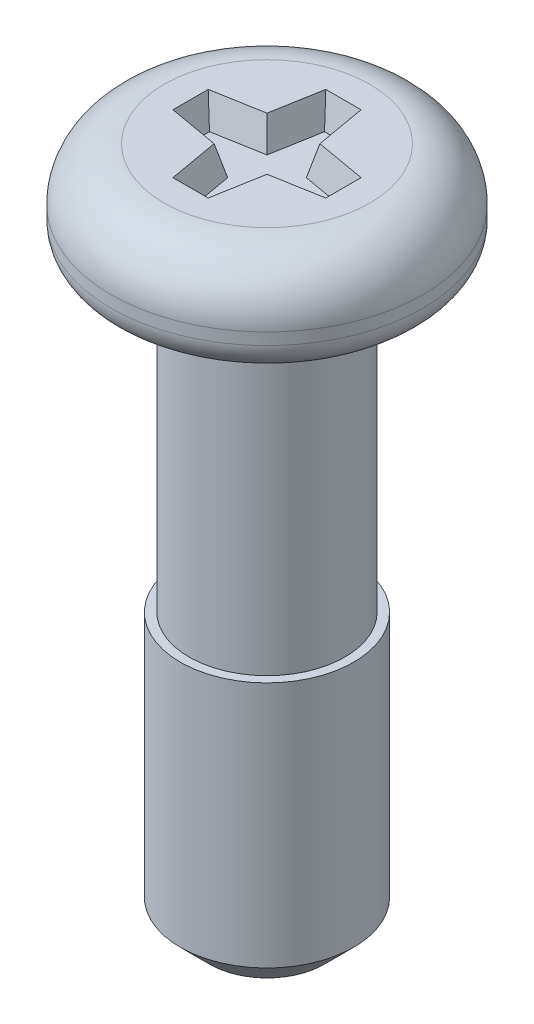
from build123d import *

# Parameters (mm, degrees)
CUT_EXTRUDE1_DEPTH = 0.5
CUT_EXTRUDE1_TAPER = 15


with BuildPart() as part:
    # Sketch1 → Revolve1 (revolve)
    with BuildSketch(Plane.XY):
        with BuildLine():
            Line((0, -11.6), (0.975, -11.6))
            Line((0.975, -11.6), (1.475, -11.1))
            Line((1.475, -11.1), (1.475, -6.9))
            Line((1.475, -6.9), (1.325, -6.9))
            Line((1.325, -6.9), (1.325, -1.75))
            ThreePointArc((1.325, -1.75), (1.368933983, -1.643933983), (1.475, -1.6))
            Line((1.475, -1.6), (2.15, -1.6))
            ThreePointArc((2.15, -1.6), (2.503553391, -1.453553391), (2.65, -1.1))
            Line((2.65, -1.1), (2.65, -0.9))
            ThreePointArc((2.65, -0.9), (2.386396103, -0.263603897), (1.75, 0))
            Line((1.75, 0), (0, 0))
            Line((0, 0), (0, -11.6))
        make_face()
    revolve(axis=Axis((0, 0, 0), (0, -1, 0)))

    # Sketch2 → Cut-Extrude1 (cut)
    with BuildSketch(Plane(origin=(0, 0, 0), x_dir=(1, 0, 0), z_dir=(0, 1, 0))):
        Polygon((-0.300122066, 1.3), (-0.45, 0.45), (-1.3, 0.300122066), (-1.3, -0.300122066), (-0.45, -0.45), (-0.300122066, -1.3), (0.300122066, -1.3), (0.45, -0.45), (1.3, -0.300122066), (1.3, 0.300122066), (0.45, 0.45), (0.300122066, 1.3), align=None)
    extrude(amount=-CUT_EXTRUDE1_DEPTH, taper=CUT_EXTRUDE1_TAPER, mode=Mode.SUBTRACT)


solid = part.part
